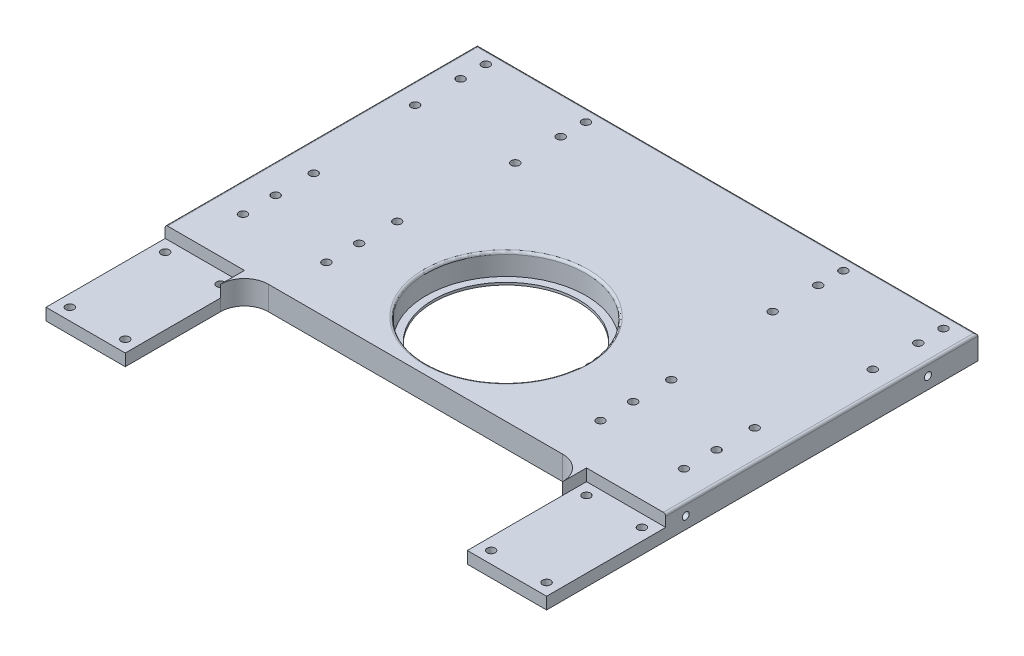
from build123d import *

# Parameters (mm, degrees)
SKIZZE1_W                        = 210
SKIZZE1_H                        = 420
AUFSATZ_LINEAR_AUSTRAGEN1_DEPTH  = 10
SKIZZE5_W                        = 210
SKIZZE5_H                        = 85
SCHNITT_LINEAR_AUSTRAGEN2_DEPTH  = 10
SKIZZE6_R                        = 1.7
SCHNITT_LINEAR_AUSTRAGEN3_DEPTH  = 11
SCHNITT_LINEAR_AUSTRAGEN4_DEPTH  = 4
SKIZZE16_W                       = 35
SKIZZE16_H                       = 7
SCHNITT_LINEAR_AUSTRAGEN10_DEPTH = 5
SCHNITT_LINEAR_AUSTRAGEN11_DEPTH = 35
SKIZZE20_R                       = 1.7
SCHNITT_LINEAR_AUSTRAGEN12_DEPTH = 11
SKIZZE21_W                       = 143.493506494
SKIZZE21_H                       = 50
SCHNITT_LINEAR_AUSTRAGEN13_DEPTH = 11
SCHNITT_LINEAR_AUSTRAGEN14_DEPTH = 11
AUFSATZ_LINEAR_AUSTRAGEN6_DEPTH  = 10
SKIZZE25_R                       = 1.7
SCHNITT_LINEAR_AUSTRAGEN15_DEPTH = 11
SCHNITT_LINEAR_AUSTRAGEN16_DEPTH = 211
SKIZZE27_R                       = 33.5
SCHNITT_LINEAR_AUSTRAGEN17_DEPTH = 11
SKIZZE28_R                       = 36.006256149
SKIZZE28_R_2                     = 30.5
AUFSATZ_LINEAR_AUSTRAGEN7_DEPTH  = 1
SKIZZE29_R                       = 1.5
SKIZZE29_R_2                     = 1.45
SCHNITT_LINEAR_AUSTRAGEN18_DEPTH = 10
SKIZZE30_R                       = 1.45
SCHNITT_LINEAR_AUSTRAGEN19_DEPTH = 10
SKIZZE31_R                       = 2.95
SCHNITT_LINEAR_AUSTRAGEN20_DEPTH = 3.5
VERRUNDUNG1_R                    = 10
AUFSATZ_LINEAR_AUSTRAGEN8_DEPTH  = 5
VERRUNDUNG2_R                    = 1
FASE1_SIZE                       = 0.62


with BuildPart() as part:
    # Skizze1 → Aufsatz-Linear austragen1 (new body)
    with BuildSketch(Plane(origin=(0, 0, 0), x_dir=(1, 0, 0), z_dir=(0, 1, 0))):
        Rectangle(SKIZZE1_W, SKIZZE1_H)
    extrude(amount=AUFSATZ_LINEAR_AUSTRAGEN1_DEPTH)

    # Skizze5 → Schnitt-Linear austragen2 (cut)
    with BuildSketch(Plane(origin=(0, 10, 0), x_dir=(1, 0, 0), z_dir=(0, 1, 0))):
        Polygon((105, -210), (18, -210), (105, -56), align=None)
        Polygon((-18, -210), (-105, -56), (-105, -210), align=None)
        with Locations((0, 167.5)):
            Rectangle(SKIZZE5_W, SKIZZE5_H)
        Polygon((71.746753247, -56), (-71.746753247, -56), (-2.824675325, -178), (2.824675325, -178), align=None)
    extrude(amount=-SCHNITT_LINEAR_AUSTRAGEN2_DEPTH, mode=Mode.SUBTRACT)

    # Skizze6 → Schnitt-Linear austragen3 (cut, through all)
    with BuildSketch(Plane(origin=(0, 10, 0), x_dir=(1, 0, 0), z_dir=(0, 1, 0))):
        with Locations((-11, -205)):
            Circle(SKIZZE6_R)
        with Locations((-11, -188.18)):
            Circle(SKIZZE6_R)
        with Locations((11, -205)):
            Circle(SKIZZE6_R)
        with Locations((11, -188.18)):
            Circle(SKIZZE6_R)
    extrude(amount=-SCHNITT_LINEAR_AUSTRAGEN3_DEPTH, mode=Mode.SUBTRACT)

    # Skizze7 → Schnitt-Linear austragen4 (cut)
    with BuildSketch(Plane.XZ):
        Polygon((-11, 208.406366588), (-8.05, 206.703183294), (-8.05, 203.296816706), (-11, 201.593633412), (-13.95, 203.296816706), (-13.95, 206.703183294), align=None)
        Polygon((11, 208.406366588), (8.05, 206.703183294), (8.05, 203.296816706), (11, 201.593633412), (13.95, 203.296816706), (13.95, 206.703183294), align=None)
        Polygon((-8.05, 186.476816706), (-8.05, 189.883183294), (-11, 191.586366588), (-13.95, 189.883183294), (-13.95, 186.476816706), (-11, 184.773633412), align=None)
        Polygon((8.05, 186.476816706), (8.05, 189.883183294), (11, 191.586366588), (13.95, 189.883183294), (13.95, 186.476816706), (11, 184.773633412), align=None)
    extrude(amount=-SCHNITT_LINEAR_AUSTRAGEN4_DEPTH, mode=Mode.SUBTRACT)

    # Skizze16 → Schnitt-Linear austragen10 (cut)
    with BuildSketch(Plane.XZ):
        with Locations((0, 196.59)):
            Rectangle(SKIZZE16_W, SKIZZE16_H)
    extrude(amount=-SCHNITT_LINEAR_AUSTRAGEN10_DEPTH, mode=Mode.SUBTRACT)

    # Skizze17 → Schnitt-Linear austragen11 (cut)
    with BuildSketch(Plane.ZY.offset(-17.5)):
        Polygon((193.09, 5), (196.59, 8.5), (200.09, 5), align=None)
    extrude(amount=SCHNITT_LINEAR_AUSTRAGEN11_DEPTH, mode=Mode.SUBTRACT)

    # Skizze20 → Schnitt-Linear austragen12 (cut, through all)
    with BuildSketch(Plane(origin=(0, 10, 0), x_dir=(1, 0, 0), z_dir=(0, 1, 0))):
        with Locations((96, 119.52)):
            Circle(SKIZZE20_R)
        with Locations((54, 119.52)):
            Circle(SKIZZE20_R)
        with Locations((-54, 119.52)):
            Circle(SKIZZE20_R)
        with Locations((-96, 119.52)):
            Circle(SKIZZE20_R)
        with Locations((92.5, 43.82)):
            Circle(SKIZZE20_R)
        with Locations((57.5, 43.82)):
            Circle(SKIZZE20_R)
        with Locations((-92.5, 43.82)):
            Circle(SKIZZE20_R)
        with Locations((-57.5, 43.82)):
            Circle(SKIZZE20_R)
        with Locations((96, 108.94)):
            Circle(SKIZZE20_R)
        with Locations((92.5, 27.84)):
            Circle(SKIZZE20_R)
        with Locations((54, 108.94)):
            Circle(SKIZZE20_R)
        with Locations((57.5, 27.84)):
            Circle(SKIZZE20_R)
        with Locations((-54, 108.94)):
            Circle(SKIZZE20_R)
        with Locations((-96, 108.94)):
            Circle(SKIZZE20_R)
        with Locations((-57.5, 27.84)):
            Circle(SKIZZE20_R)
        with Locations((-92.5, 27.84)):
            Circle(SKIZZE20_R)
        with Locations((96, 89.84)):
            Circle(SKIZZE20_R)
        with Locations((92.5, 14.13)):
            Circle(SKIZZE20_R)
        with Locations((57.5, 14.13)):
            Circle(SKIZZE20_R)
        with Locations((54, 89.84)):
            Circle(SKIZZE20_R)
        with Locations((-96, 89.84)):
            Circle(SKIZZE20_R)
        with Locations((-54, 89.84)):
            Circle(SKIZZE20_R)
        with Locations((-57.5, 14.13)):
            Circle(SKIZZE20_R)
        with Locations((-92.5, 14.13)):
            Circle(SKIZZE20_R)
    extrude(amount=-SCHNITT_LINEAR_AUSTRAGEN12_DEPTH, mode=Mode.SUBTRACT)

    # Skizze21 → Schnitt-Linear austragen13 (cut, through all)
    with BuildSketch(Plane(origin=(0, 10, 0), x_dir=(1, 0, 0), z_dir=(0, 1, 0))):
        with Locations((0, -31)):
            Rectangle(SKIZZE21_W, SKIZZE21_H)
    extrude(amount=-SCHNITT_LINEAR_AUSTRAGEN13_DEPTH, mode=Mode.SUBTRACT)

    # Skizze22 → Schnitt-Linear austragen14 (cut, through all)
    with BuildSketch(Plane(origin=(0, 10, 0), x_dir=(1, 0, 0), z_dir=(0, 1, 0))):
        with BuildLine():
            Line((-71.746753247, -56), (-2.824675325, -178))
            ThreePointArc((-2.824675325, -178), (-55.506711033, -127.293679981), (-71.746753247, -56))
        make_face()
    schnitt_linear_austragen14 = extrude(amount=-SCHNITT_LINEAR_AUSTRAGEN14_DEPTH, mode=Mode.SUBTRACT)

    # Skizze23 → Aufsatz-Linear austragen6 (add)
    with BuildSketch(Plane(origin=(0, 10, 0), x_dir=(1, 0, 0), z_dir=(0, 1, 0))):
        with BuildLine():
            Line((-105, -56), (-18, -210))
            ThreePointArc((-18, -210), (-78.088357737, -142.371344955), (-105, -56))
        make_face()
    aufsatz_linear_austragen6 = extrude(amount=-AUFSATZ_LINEAR_AUSTRAGEN6_DEPTH)

    # Spiegeln2: Schnitt-Linear austragen14, Aufsatz-Linear austragen6 across plane
    add(schnitt_linear_austragen14.mirror(Plane(origin=(0, 0, 0), x_dir=(0, 0, 1), z_dir=(1, 0, 0))), mode=Mode.SUBTRACT)
    add(aufsatz_linear_austragen6.mirror(Plane(origin=(0, 0, 0), x_dir=(0, 0, 1), z_dir=(1, 0, 0))))

    # Skizze25 → Schnitt-Linear austragen15 (cut, through all)
    with BuildSketch(Plane(origin=(0, 10, 0), x_dir=(1, 0, 0), z_dir=(0, 1, 0))):
        with Locations((-100, -11)):
            Circle(SKIZZE25_R)
        with Locations((-76.746753247, -11)):
            Circle(SKIZZE25_R)
        with Locations((-76.746753247, -51)):
            Circle(SKIZZE25_R)
        with Locations((-100, -51)):
            Circle(SKIZZE25_R)
    schnitt_linear_austragen15 = extrude(amount=-SCHNITT_LINEAR_AUSTRAGEN15_DEPTH, mode=Mode.SUBTRACT)

    # Spiegeln3: Schnitt-Linear austragen15 across plane
    add(schnitt_linear_austragen15.mirror(Plane(origin=(0, 0, 0), x_dir=(0, 0, 1), z_dir=(1, 0, 0))), mode=Mode.SUBTRACT)

    # Skizze26 → Schnitt-Linear austragen16 (cut, through all)
    with BuildSketch(Plane.ZY.offset(105)):
        Polygon((6, 5), (6, 13.101486595), (200.684563047, 82.546277137), (242.997216492, -41.037631402), (91.241487897, -60.284782055), (56, 0), (56, 5), align=None)
    extrude(amount=-SCHNITT_LINEAR_AUSTRAGEN16_DEPTH, mode=Mode.SUBTRACT)

    # Skizze27 → Schnitt-Linear austragen17 (cut, through all)
    with BuildSketch(Plane(origin=(0, 10, 0), x_dir=(1, 0, 0), z_dir=(0, 1, 0))):
        with Locations((0, 32)):
            Circle(SKIZZE27_R)
    extrude(amount=-SCHNITT_LINEAR_AUSTRAGEN17_DEPTH, mode=Mode.SUBTRACT)

    # Skizze28 → Aufsatz-Linear austragen7 (add)
    with BuildSketch(Plane.XZ):
        with Locations((0, -32)):
            Circle(SKIZZE28_R)
        with Locations((0, -32)):
            Circle(SKIZZE28_R_2, mode=Mode.SUBTRACT)
    extrude(amount=-AUFSATZ_LINEAR_AUSTRAGEN7_DEPTH)

    # Skizze29 → Schnitt-Linear austragen18 (cut)
    with BuildSketch(Plane.ZY.offset(105)):
        with Locations((-104, 5)):
            Circle(SKIZZE29_R)
        with Locations((-2.4, 5)):
            Circle(SKIZZE29_R_2)
    schnitt_linear_austragen18 = extrude(amount=-SCHNITT_LINEAR_AUSTRAGEN18_DEPTH, mode=Mode.SUBTRACT)

    # Skizze30 → Schnitt-Linear austragen19 (cut)
    with BuildSketch(Plane(origin=(0, 0, -125), x_dir=(-1, 0, 0), z_dir=(0, 0, -1))):
        with Locations((100, 5)):
            Circle(SKIZZE30_R)
        with Locations((84, 5)):
            Circle(SKIZZE30_R)
    schnitt_linear_austragen19 = extrude(amount=-SCHNITT_LINEAR_AUSTRAGEN19_DEPTH, mode=Mode.SUBTRACT)

    # Spiegeln4: Schnitt-Linear austragen18, Schnitt-Linear austragen19 across plane
    add(schnitt_linear_austragen18.mirror(Plane(origin=(0, 0, 0), x_dir=(0, 0, 1), z_dir=(1, 0, 0))), mode=Mode.SUBTRACT)
    add(schnitt_linear_austragen19.mirror(Plane(origin=(0, 0, 0), x_dir=(0, 0, 1), z_dir=(1, 0, 0))), mode=Mode.SUBTRACT)

    # Skizze31 → Schnitt-Linear austragen20 (cut)
    with BuildSketch(Plane.XZ):
        with Locations((-96, -119.52)):
            Circle(SKIZZE31_R)
        with Locations((-54, -119.52)):
            Circle(SKIZZE31_R)
        with Locations((-92.5, -43.82)):
            Circle(SKIZZE31_R)
        with Locations((-57.5, -43.82)):
            Circle(SKIZZE31_R)
        with Locations((57.5, -43.82)):
            Circle(SKIZZE31_R)
        with Locations((92.5, -43.82)):
            Circle(SKIZZE31_R)
        with Locations((54, -119.52)):
            Circle(SKIZZE31_R)
        with Locations((96, -119.52)):
            Circle(SKIZZE31_R)
        with Locations((-96, -108.94)):
            Circle(SKIZZE31_R)
        with Locations((-96, -89.84)):
            Circle(SKIZZE31_R)
        with Locations((-54, -89.84)):
            Circle(SKIZZE31_R)
        with Locations((-54, -108.94)):
            Circle(SKIZZE31_R)
        with Locations((-92.5, -14.13)):
            Circle(SKIZZE31_R)
        with Locations((-92.5, -27.84)):
            Circle(SKIZZE31_R)
        with Locations((-57.5, -27.84)):
            Circle(SKIZZE31_R)
        with Locations((-57.5, -14.13)):
            Circle(SKIZZE31_R)
        with Locations((54, -108.94)):
            Circle(SKIZZE31_R)
        with Locations((54, -89.84)):
            Circle(SKIZZE31_R)
        with Locations((96, -89.84)):
            Circle(SKIZZE31_R)
        with Locations((96, -108.94)):
            Circle(SKIZZE31_R)
        with Locations((57.5, -14.13)):
            Circle(SKIZZE31_R)
        with Locations((57.5, -27.84)):
            Circle(SKIZZE31_R)
        with Locations((92.5, -27.84)):
            Circle(SKIZZE31_R)
        with Locations((92.5, -14.13)):
            Circle(SKIZZE31_R)
    extrude(amount=-SCHNITT_LINEAR_AUSTRAGEN20_DEPTH, mode=Mode.SUBTRACT)

    # Verrundung1
    verrundung1_edges = [part.edges().sort_by_distance(p)[0] for p in [
        (-71.746753247, 2.5, 6),
        (71.746753247, 2.5, 6),
    ]]
    fillet(verrundung1_edges, radius=VERRUNDUNG1_R)

    # Skizze33 → Aufsatz-Linear austragen8 (add)
    with BuildSketch(Plane(origin=(0, 5, 0), x_dir=(1, 0, 0), z_dir=(0, 1, 0))):
        with BuildLine():
            Line((-71.746753247, -16), (-71.746753247, -6))
            Line((-71.746753247, -6), (-61.746753247, -6))
            ThreePointArc((-61.746753247, -6), (-68.817821059, -8.928932188), (-71.746753247, -16))
        make_face()
        with BuildLine():
            Line((71.746753247, -6), (61.746753247, -6))
            ThreePointArc((61.746753247, -6), (68.817821059, -8.928932188), (71.746753247, -16))
            Line((71.746753247, -16), (71.746753247, -6))
        make_face()
    extrude(amount=AUFSATZ_LINEAR_AUSTRAGEN8_DEPTH)

    # Verrundung2
    verrundung2_edges = [part.edges().sort_by_distance(p)[0] for p in [
        (-105, 10, -59.5),
        (105, 10, -59.5),
        (0, 10, -125),
        (-33.5, 10, -32),
    ]]
    fillet(verrundung2_edges, radius=VERRUNDUNG2_R)

    # Fase1
    fase1_edges = [part.edges().sort_by_distance(p)[0] for p in [
        (-98.95, 3.5, -119.52),
        (-97.7, 3.5, -119.52),
        (52.3, 3.5, -89.84),
        (51.05, 3.5, -89.84),
        (52.3, 3.5, -108.94),
        (51.05, 3.5, -108.94),
        (-60.45, 3.5, -14.13),
        (-59.2, 3.5, -14.13),
        (-60.45, 3.5, -27.84),
        (-59.2, 3.5, -27.84),
        (-95.45, 3.5, -27.84),
        (-94.2, 3.5, -27.84),
        (-95.45, 3.5, -14.13),
        (-94.2, 3.5, -14.13),
        (90.8, 3.5, -14.13),
        (89.55, 3.5, -14.13),
        (90.8, 3.5, -27.84),
        (89.55, 3.5, -27.84),
        (55.8, 3.5, -27.84),
        (54.55, 3.5, -27.84),
        (94.3, 3.5, -89.84),
        (93.05, 3.5, -89.84),
        (94.3, 3.5, -108.94),
        (93.05, 3.5, -108.94),
        (55.8, 3.5, -14.13),
        (54.55, 3.5, -14.13),
        (90.8, 3.5, -43.82),
        (89.55, 3.5, -43.82),
        (55.8, 3.5, -43.82),
        (54.55, 3.5, -43.82),
        (-60.45, 3.5, -43.82),
        (-59.2, 3.5, -43.82),
        (-95.45, 3.5, -43.82),
        (-94.2, 3.5, -43.82),
        (-56.95, 3.5, -119.52),
        (-56.95, 3.5, -108.94),
        (-55.7, 3.5, -108.94),
        (-56.95, 3.5, -89.84),
        (-55.7, 3.5, -89.84),
        (-98.95, 3.5, -89.84),
        (-97.7, 3.5, -89.84),
        (52.3, 3.5, -119.52),
        (51.05, 3.5, -119.52),
        (94.3, 3.5, -119.52),
        (93.05, 3.5, -119.52),
        (-98.95, 3.5, -108.94),
        (-97.7, 3.5, -108.94),
    ]]
    chamfer(fase1_edges, length=FASE1_SIZE)


solid = part.part
